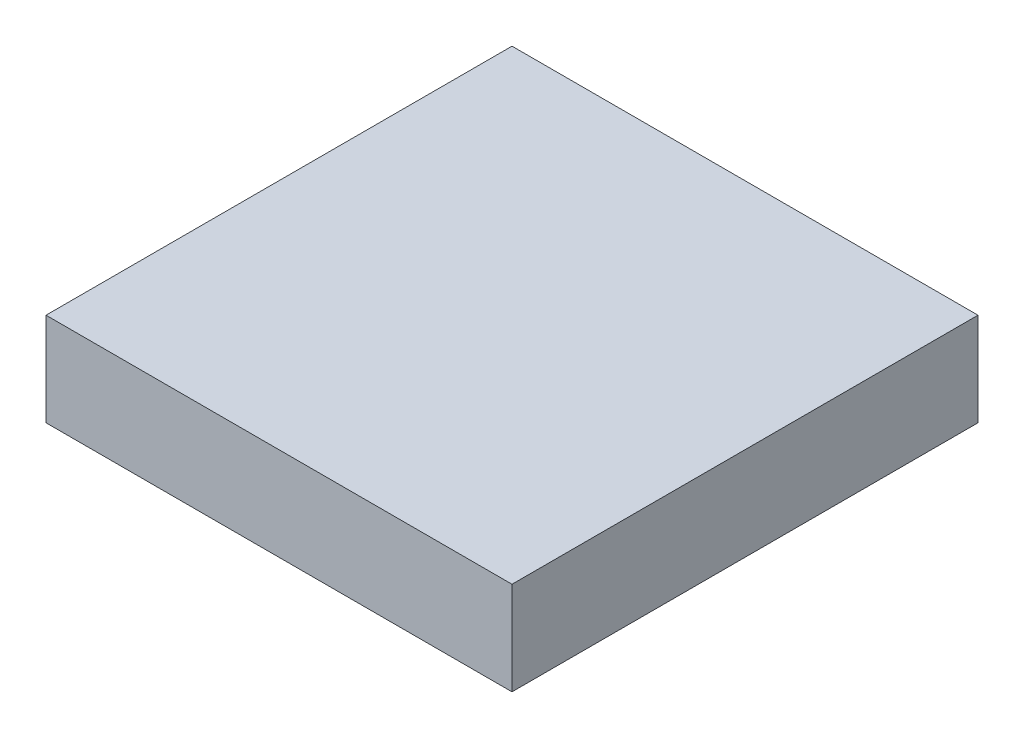
from build123d import *

# Parameters (mm, degrees)
SKETCH1_W           = 15
SKETCH1_H           = 15
BOSS_EXTRUDE1_DEPTH = 3
SKETCH2_R           = 6
SKETCH2_R_2         = 2.5
CUT_EXTRUDE1_DEPTH  = 2
SKETCH3_R           = 1.25
CUT_EXTRUDE2_DEPTH  = 2


with BuildPart() as part:
    # Sketch1 → Boss-Extrude1 (new body)
    with BuildSketch(Plane(origin=(0, 0, 0), x_dir=(1, 0, 0), z_dir=(0, 1, 0))):
        Rectangle(SKETCH1_W, SKETCH1_H)
    extrude(amount=BOSS_EXTRUDE1_DEPTH)

    # Sketch2 → Cut-Extrude1 (cut)
    with BuildSketch(Plane.XZ):
        Circle(SKETCH2_R)
        Circle(SKETCH2_R_2, mode=Mode.SUBTRACT)
    extrude(amount=-CUT_EXTRUDE1_DEPTH, mode=Mode.SUBTRACT)

    # Sketch3 → Cut-Extrude2 (cut)
    with BuildSketch(Plane.XZ):
        with Locations((5.5, 5.5)):
            Circle(SKETCH3_R)
        with Locations((-5.5, 5.5)):
            Circle(SKETCH3_R)
        with Locations((-5.5, -5.5)):
            Circle(SKETCH3_R)
        with Locations((5.5, -5.5)):
            Circle(SKETCH3_R)
    extrude(amount=-CUT_EXTRUDE2_DEPTH, mode=Mode.SUBTRACT)


solid = part.part
